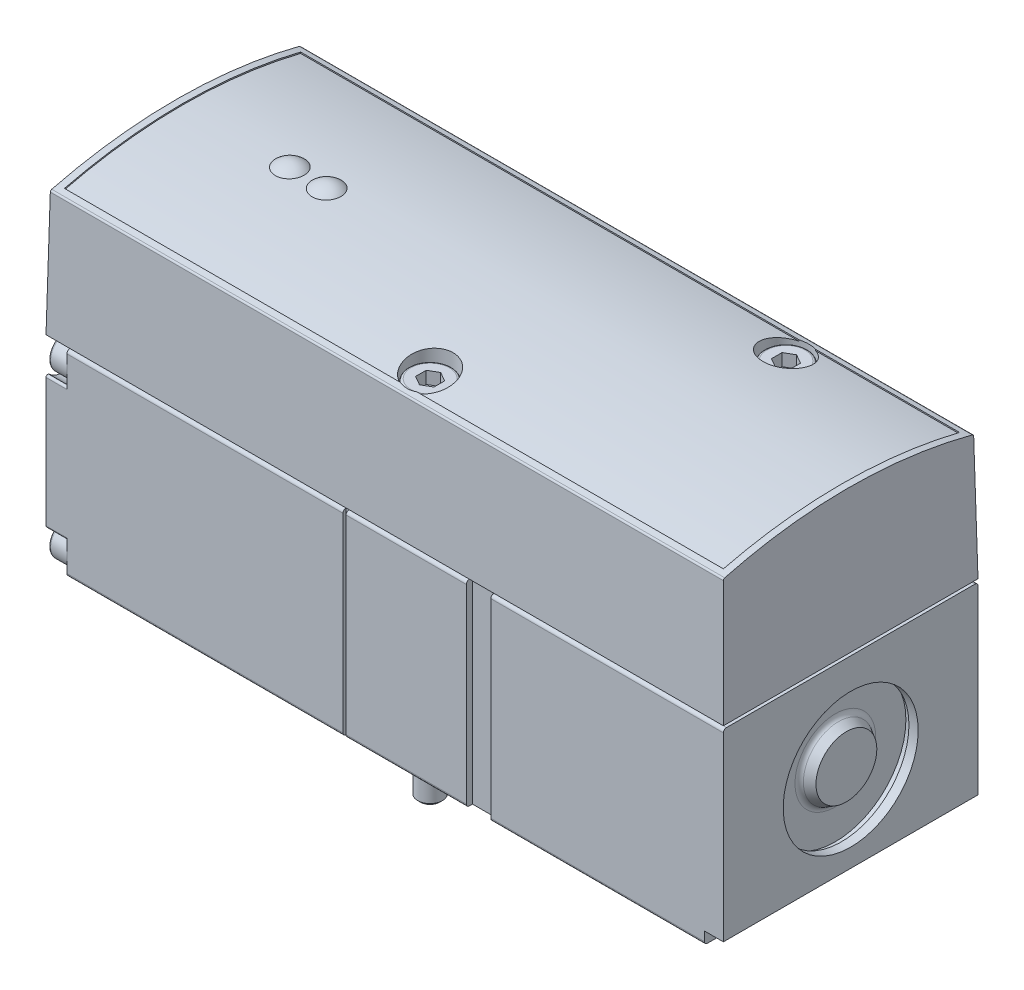
from build123d import *

# Parameters (mm, degrees)
BOSS_EXTRUDE1_DEPTH     = 110.4
SKETCH2_W               = 50
SKETCH2_H               = 40
SKETCH2_W_2             = 40.5
SKETCH2_H_2             = 32
CUT_EXTRUDE1_DEPTH      = 0.5
SKETCH3_W               = 39.7
SKETCH3_H               = 2
BOSS_EXTRUDE2_DEPTH     = 108.6
BOSS_EXTRUDE3_DEPTH     = 110.4
SKETCH5_W               = 107.4
SKETCH5_H               = 38.5
CUT_EXTRUDE2_DEPTH      = 10
BOSS_EXTRUDE4_DEPTH     = 110.4
CUT_EXTRUDE3_DEPTH      = 22
CUT_EXTRUDE3_DEPTH_BACK = 22
CUT_EXTRUDE4_DEPTH      = 3.4
CUT_EXTRUDE5_DEPTH      = 1.3
CUT_EXTRUDE6_DEPTH      = 1.3
CUT_EXTRUDE7_DEPTH      = 1.3
CUT_EXTRUDE8_DEPTH      = 1.3
CUT_EXTRUDE9_DEPTH      = 2
CUT_EXTRUDE10_DEPTH     = 2
SKETCH24_R              = 3
CUT_EXTRUDE11_DEPTH     = 16
CUT_EXTRUDE12_DEPTH     = 5.5
CUT_EXTRUDE13_DEPTH     = 0.4
SKETCH27_R              = 3
CUT_EXTRUDE14_DEPTH     = 16
SKETCH28_R              = 3
CUT_EXTRUDE15_DEPTH     = 16
CUT_EXTRUDE16_DEPTH     = 5.5
SKETCH30_W              = 41.5
SKETCH30_H              = 2
CUT_EXTRUDE17_DEPTH     = 3.1
CUT_EXTRUDE18_DEPTH     = 4
CUT_EXTRUDE19_DEPTH     = 4
CUT_EXTRUDE20_DEPTH     = 6.2
BOSS_EXTRUDE5_DEPTH     = 8.5
CUT_EXTRUDE21_DEPTH     = 3


with BuildPart() as part:
    # Sketch1 → Boss-Extrude1 (new body)
    with BuildSketch(Plane(origin=(0, 0, 0), x_dir=(0, 0, -1), z_dir=(1, 0, 0))):
        with BuildLine():
            Line((-20.75, 31.5), (-20.75, 0.5))
            ThreePointArc((-20.75, 0.5), (-20.603553391, 0.146446609), (-20.25, 0))
            Line((-20.25, 0), (20.25, 0))
            ThreePointArc((20.25, 0), (20.603553391, 0.146446609), (20.75, 0.5))
            Line((20.75, 0.5), (20.75, 31.5))
            ThreePointArc((20.75, 31.5), (20.603553391, 31.853553391), (20.25, 32))
            Line((20.25, 32), (-20.25, 32))
            ThreePointArc((-20.25, 32), (-20.603553391, 31.853553391), (-20.75, 31.5))
        make_face()
    extrude(amount=-BOSS_EXTRUDE1_DEPTH)

    # Sketch2 → Cut-Extrude1 (cut)
    with BuildSketch(Plane(origin=(-61.5, 0, 0), x_dir=(0, 0, -1), z_dir=(1, 0, 0))):
        with Locations((0, 19)):
            Rectangle(SKETCH2_W, SKETCH2_H)
        with Locations((0, 16.5)):
            Rectangle(SKETCH2_W_2, SKETCH2_H_2, mode=Mode.SUBTRACT)
    extrude(amount=-CUT_EXTRUDE1_DEPTH, mode=Mode.SUBTRACT)

    # Sketch3 → Boss-Extrude2 (add)
    with BuildSketch(Plane(origin=(-0.9, 0, 0), x_dir=(0, 0, -1), z_dir=(1, 0, 0))):
        with Locations((0, 32.5)):
            Rectangle(SKETCH3_W, SKETCH3_H)
    extrude(amount=-BOSS_EXTRUDE2_DEPTH)

    # Sketch4 → Boss-Extrude3 (add)
    with BuildSketch(Plane(origin=(0, 0, 0), x_dir=(0, 0, -1), z_dir=(1, 0, 0))):
        with BuildLine():
            Line((-20.75, 32.5), (20.75, 32.5))
            Line((20.75, 32.5), (20.398523638, 52.636067289))
            ThreePointArc((20.398523638, 52.636067289), (20.334276266, 52.816417774), (20.174033257, 52.921185137))
            ThreePointArc((20.174033257, 52.921185137), (-1.9e-08, 55.5), (-20.174033294, 52.921185128))
            ThreePointArc((-20.174033294, 52.921185128), (-20.334276278, 52.816417759), (-20.398523638, 52.636067289))
            Line((-20.398523638, 52.636067289), (-20.75, 32.5))
        make_face()
    extrude(amount=-BOSS_EXTRUDE3_DEPTH)

    # Sketch5 → Cut-Extrude2 (cut)
    with BuildSketch(Plane(origin=(0, 56, 0), x_dir=(1, 0, 0), z_dir=(0, 1, 0))):
        with Locations((-55.2, 0)):
            Rectangle(SKETCH5_W, SKETCH5_H)
    extrude(amount=-CUT_EXTRUDE2_DEPTH, mode=Mode.SUBTRACT)

    # Sketch6 → Boss-Extrude4 (add)
    with BuildSketch(Plane(origin=(0, 0, 0), x_dir=(0, 0, -1), z_dir=(1, 0, 0))):
        with BuildLine():
            Line((-20.75, 32.5), (20.75, 32.5))
            Line((20.75, 32.5), (20.402147424, 52.428460706))
            ThreePointArc((20.402147424, 52.428460706), (20.337964945, 52.608728743), (20.177860123, 52.713525697))
            ThreePointArc((20.177860123, 52.713525697), (1.7e-08, 55.3), (-20.177860091, 52.713525705))
            ThreePointArc((-20.177860091, 52.713525705), (-20.337964935, 52.608728756), (-20.402147424, 52.428460706))
            Line((-20.402147424, 52.428460706), (-20.75, 32.5))
        make_face()
    extrude(amount=-BOSS_EXTRUDE4_DEPTH)

    # Sketch7 → Cut-Extrude3 (cut, two sides)
    with BuildSketch(Plane.XY) as cut_extrude3_sk:
        Polygon((-111.4, 32.5), (-110.4, 32.5), (-109.789072728, 67.5), (-0.610927272, 67.5), (0, 32.5), (1, 32.5), (1, 70), (-111.4, 70), align=None)
    extrude(amount=CUT_EXTRUDE3_DEPTH, mode=Mode.SUBTRACT)
    extrude(cut_extrude3_sk.sketch, amount=-CUT_EXTRUDE3_DEPTH_BACK, mode=Mode.SUBTRACT)

    # Sketch8 → Cut-Extrude4 (cut)
    with BuildSketch(Plane(origin=(-110.4, 0, 0), x_dir=(0, 0, -1), z_dir=(1, 0, 0))):
        with BuildLine():
            Line((-23, 32), (-23, -1))
            Line((-23, -1), (23, -1))
            Line((23, -1), (23, 32))
            Line((23, 32), (15.222363661, 32))
            ThreePointArc((15.222363661, 32), (15.496964107, 31.82080809), (15.443523364, 31.497297297))
            ThreePointArc((15.443523364, 31.497297297), (15.545836944, 26.795836944), (20.247297297, 26.693523364))
            ThreePointArc((20.247297297, 26.693523364), (20.57080809, 26.746964107), (20.75, 26.472363661))
            Line((20.75, 26.472363661), (20.75, 5.527636339))
            ThreePointArc((20.75, 5.527636339), (20.57080809, 5.253035893), (20.247297297, 5.306476636))
            ThreePointArc((20.247297297, 5.306476636), (15.545836944, 5.204163056), (15.443523364, 0.502702703))
            ThreePointArc((15.443523364, 0.502702703), (15.496964107, 0.17919191), (15.222363661, 0))
            Line((15.222363661, 0), (-15.222363661, 0))
            ThreePointArc((-15.222363661, 0), (-15.496964121, 0.179191941), (-15.443523319, 0.502702752))
            ThreePointArc((-15.443523319, 0.502702752), (-15.545836967, 5.20416308), (-20.247297297, 5.306476636))
            ThreePointArc((-20.247297297, 5.306476636), (-20.57080809, 5.253035893), (-20.75, 5.527636339))
            Line((-20.75, 5.527636339), (-20.75, 26.472363661))
            ThreePointArc((-20.75, 26.472363661), (-20.57080809, 26.746964107), (-20.247297297, 26.693523364))
            ThreePointArc((-20.247297297, 26.693523364), (-15.545836944, 26.795836944), (-15.443523364, 31.497297297))
            ThreePointArc((-15.443523364, 31.497297297), (-15.496964107, 31.82080809), (-15.222363661, 32))
            Line((-15.222363661, 32), (-23, 32))
        make_face()
    extrude(amount=CUT_EXTRUDE4_DEPTH, mode=Mode.SUBTRACT)

    # Sketch9 → Revolve1 (revolve)
    with BuildSketch(Plane.XY.offset(-17.95)):
        with BuildLine():
            Line((-110, 2.8), (-110, 5.25))
            ThreePointArc((-110, 5.25), (-109.912132034, 5.462132034), (-109.7, 5.55))
            Line((-109.7, 5.55), (-107, 5.55))
            Line((-107, 5.55), (-107, 2.8))
            Line((-107, 2.8), (-110, 2.8))
        make_face()
    revolve(axis=Axis((-107, 2.8, -17.95), (-1, 0, 0)))

    # Sketch10 → Revolve2 (revolve)
    with BuildSketch(Plane.XY.offset(-17.95)):
        with BuildLine():
            Line((-110, 29.2), (-110, 31.65))
            ThreePointArc((-110, 31.65), (-109.912132034, 31.862132034), (-109.7, 31.95))
            Line((-109.7, 31.95), (-107, 31.95))
            Line((-107, 31.95), (-107, 29.2))
            Line((-107, 29.2), (-110, 29.2))
        make_face()
    revolve(axis=Axis((-107, 29.2, -17.95), (-1, 0, 0)))

    # Sketch11 → Revolve3 (revolve)
    with BuildSketch(Plane.XY.offset(17.95)):
        with BuildLine():
            Line((-110, 2.8), (-110, 5.25))
            ThreePointArc((-110, 5.25), (-109.912132034, 5.462132034), (-109.7, 5.55))
            Line((-109.7, 5.55), (-107, 5.55))
            Line((-107, 5.55), (-107, 2.8))
            Line((-107, 2.8), (-110, 2.8))
        make_face()
    revolve(axis=Axis((-107, 2.8, 17.95), (-1, 0, 0)))

    # Sketch12 → Revolve4 (revolve)
    with BuildSketch(Plane.XY.offset(17.95)):
        with BuildLine():
            Line((-110, 29.2), (-110, 31.65))
            ThreePointArc((-110, 31.65), (-109.912132034, 31.862132034), (-109.7, 31.95))
            Line((-109.7, 31.95), (-107, 31.95))
            Line((-107, 31.95), (-107, 29.2))
            Line((-107, 29.2), (-110, 29.2))
        make_face()
    revolve(axis=Axis((-107, 29.2, 17.95), (-1, 0, 0)))

    # Sketch13 → Cut-Extrude5 (cut)
    with BuildSketch(Plane(origin=(-110, 0, 0), x_dir=(0, 0, -1), z_dir=(1, 0, 0))):
        Polygon((16.7, 3.521687836), (16.7, 2.078312164), (17.95, 1.356624327), (19.2, 2.078312164), (19.2, 3.521687836), (17.95, 4.243375673), align=None)
    extrude(amount=CUT_EXTRUDE5_DEPTH, mode=Mode.SUBTRACT)

    # Sketch14 → Cut-Extrude6 (cut)
    with BuildSketch(Plane(origin=(-110, 0, 0), x_dir=(0, 0, -1), z_dir=(1, 0, 0))):
        Polygon((-19.2, 3.521687836), (-19.2, 2.078312164), (-17.95, 1.356624327), (-16.7, 2.078312164), (-16.7, 3.521687836), (-17.95, 4.243375673), align=None)
    extrude(amount=CUT_EXTRUDE6_DEPTH, mode=Mode.SUBTRACT)

    # Sketch15 → Cut-Extrude7 (cut)
    with BuildSketch(Plane(origin=(-110, 0, 0), x_dir=(0, 0, -1), z_dir=(1, 0, 0))):
        Polygon((16.7, 29.921687836), (16.7, 28.478312164), (17.95, 27.756624327), (19.2, 28.478312164), (19.2, 29.921687836), (17.95, 30.643375673), align=None)
    extrude(amount=CUT_EXTRUDE7_DEPTH, mode=Mode.SUBTRACT)

    # Sketch16 → Cut-Extrude8 (cut)
    with BuildSketch(Plane(origin=(-110, 0, 0), x_dir=(0, 0, -1), z_dir=(1, 0, 0))):
        Polygon((-19.2, 29.921687836), (-19.2, 28.478312164), (-17.95, 27.756624327), (-16.7, 28.478312164), (-16.7, 29.921687836), (-17.95, 30.643375673), align=None)
    extrude(amount=CUT_EXTRUDE8_DEPTH, mode=Mode.SUBTRACT)

    # Sketch17 → Cut-Revolve1 (revolve, cut)
    with BuildSketch(Plane(origin=(-52.8, 0, 0), x_dir=(0, 0, -1), z_dir=(1, 0, 0))):
        Polygon((-15.75, -11.4), (-17.95, -11.4), (-17.95, 48.6), (-19.5, 48.6), (-19.5, 56.6), (-15.75, 56.6), align=None)
    revolve(axis=Axis((-52.8, 56.6, 15.75), (0, -1, 0)), mode=Mode.SUBTRACT)

    # Sketch18 → Cut-Revolve2 (revolve, cut)
    with BuildSketch(Plane(origin=(-26.3, 0, 0), x_dir=(0, 0, -1), z_dir=(1, 0, 0))):
        Polygon((15.75, -11.4), (13.55, -11.4), (13.55, 48.6), (12, 48.6), (12, 56.6), (15.75, 56.6), align=None)
    revolve(axis=Axis((-26.3, 56.6, -15.75), (0, -1, 0)), mode=Mode.SUBTRACT)

    # Sketch19 → Revolve5 (revolve)
    with BuildSketch(Plane(origin=(-52.8, 0, 0), x_dir=(0, 0, -1), z_dir=(1, 0, 0))):
        with BuildLine():
            Line((-15.75, -6.4), (-17.3205, -6.4))
            Line((-17.3205, -6.4), (-17.75, -5.9705))
            Line((-17.75, -5.9705), (-17.75, 48.6))
            Line((-17.75, 48.6), (-19.25, 48.6))
            Line((-19.25, 48.6), (-19.25, 52.2))
            ThreePointArc((-19.25, 52.2), (-19.132842712, 52.482842712), (-18.85, 52.6))
            Line((-18.85, 52.6), (-15.75, 52.6))
            Line((-15.75, 52.6), (-15.75, -6.4))
        make_face()
    revolve(axis=Axis((-52.8, 52.6, 15.75), (0, -1, 0)))

    # Sketch20 → Revolve6 (revolve)
    with BuildSketch(Plane(origin=(-26.3, 0, 0), x_dir=(0, 0, -1), z_dir=(1, 0, 0))):
        with BuildLine():
            Line((15.75, -6.4), (14.1795, -6.4))
            Line((14.1795, -6.4), (13.75, -5.9705))
            Line((13.75, -5.9705), (13.75, 48.6))
            Line((13.75, 48.6), (12.25, 48.6))
            Line((12.25, 48.6), (12.25, 52.2))
            ThreePointArc((12.25, 52.2), (12.367157288, 52.482842712), (12.65, 52.6))
            Line((12.65, 52.6), (15.75, 52.6))
            Line((15.75, 52.6), (15.75, -6.4))
        make_face()
    revolve(axis=Axis((-26.3, 52.6, -15.75), (0, -1, 0)))

    # Sketch21 → Cut-Extrude9 (cut)
    with BuildSketch(Plane(origin=(0, 52.6, 0), x_dir=(1, 0, 0), z_dir=(0, 1, 0))):
        Polygon((-54.3, -16.616025404), (-52.8, -17.482050808), (-51.3, -16.616025404), (-51.3, -14.883974596), (-52.8, -14.017949192), (-54.3, -14.883974596), align=None)
    extrude(amount=-CUT_EXTRUDE9_DEPTH, mode=Mode.SUBTRACT)

    # Sketch22 → Cut-Extrude10 (cut)
    with BuildSketch(Plane(origin=(0, 52.6, 0), x_dir=(1, 0, 0), z_dir=(0, 1, 0))):
        Polygon((-27.8, 14.883974596), (-26.3, 14.017949192), (-24.8, 14.883974596), (-24.8, 16.616025404), (-26.3, 17.482050808), (-27.8, 16.616025404), align=None)
    extrude(amount=-CUT_EXTRUDE10_DEPTH, mode=Mode.SUBTRACT)

    # Sketch23 → Cut-Revolve3 (revolve, cut)
    with BuildSketch(Plane.XY):
        with BuildLine():
            Line((-0.7, 16), (-0.7, 20.960769515))
            Line((-0.7, 20.960769515), (-2, 21.711324865))
            ThreePointArc((-2, 21.711324865), (-2.366025404, 22.077350269), (-2.5, 22.577350269))
            Line((-2.5, 22.577350269), (-2.5, 27.5))
            Line((-2.5, 27.5), (-1.5, 27.5))
            Line((-1.5, 27.5), (-1.5, 27))
            Line((-1.5, 27), (0, 27))
            Line((0, 27), (0, 16))
            Line((0, 16), (-0.7, 16))
        make_face()
    revolve(axis=Axis((0, 16, 0), (-1, 0, 0)), mode=Mode.SUBTRACT)

    # Sketch24 → Cut-Extrude11 (cut)
    with BuildSketch(Plane(origin=(0, 0, 0), x_dir=(1, 0, 0), z_dir=(0, 1, 0))):
        with Locations((-12.2, -7.6)):
            Circle(SKETCH24_R)
    extrude(amount=CUT_EXTRUDE11_DEPTH, mode=Mode.SUBTRACT)

    # Sketch25 → Cut-Extrude12 (cut)
    with BuildSketch(Plane(origin=(0, 0, 0), x_dir=(1, 0, 0), z_dir=(0, 1, 0))):
        with BuildLine():
            Line((-21.921320344, -2.121320344), (-14.321320344, -9.721320344))
            ThreePointArc((-14.321320344, -9.721320344), (-10.078679656, -9.721320344), (-10.078679656, -5.478679656))
            Line((-10.078679656, -5.478679656), (-17.678679656, 2.121320344))
            ThreePointArc((-17.678679656, 2.121320344), (-21.921320292, 2.121320292), (-21.921320344, -2.121320344))
        make_face()
    extrude(amount=CUT_EXTRUDE12_DEPTH, mode=Mode.SUBTRACT)

    # Sketch26 → Cut-Extrude13 (cut)
    with BuildSketch(Plane(origin=(0, 0, 0), x_dir=(1, 0, 0), z_dir=(0, 1, 0))):
        with BuildLine():
            Line((-41.3, 1.25), (-39.3, 1.25))
            Line((-39.3, 1.25), (-39.3, -1.694671206))
            ThreePointArc((-39.3, -1.694671206), (-43.937966579, -9.769619282), (-36.8, -15.75))
            Line((-36.8, -15.75), (-28.3, -15.75))
            ThreePointArc((-28.3, -15.75), (-25.525545115, -15.198126611), (-23.173475836, -13.626524164))
            Line((-23.173475836, -13.626524164), (-19.8, -10.253048327))
            Line((-19.8, -10.253048327), (-17.326524164, -12.726524164))
            ThreePointArc((-17.326524164, -12.726524164), (-7.073475836, -12.726524164), (-7.073475836, -2.473475836))
            Line((-7.073475836, -2.473475836), (-14.674873734, 5.127922061))
            ThreePointArc((-14.674873734, 5.127922061), (-22.509952189, 6.72644315), (-27.05, 0.14376209))
            Line((-27.05, 0.14376209), (-27.05, -1.25))
            Line((-27.05, -1.25), (-36.8, -1.25))
            Line((-36.8, -1.25), (-36.8, 1.694671206))
            ThreePointArc((-36.8, 1.694671206), (-32.162033421, 9.769619282), (-39.3, 15.75))
            Line((-39.3, 15.75), (-41.3, 15.75))
            ThreePointArc((-41.3, 15.75), (-48.55, 8.5), (-41.3, 1.25))
        make_face()
        with BuildLine():
            Line((-24.55, -0.11383263), (-24.55, -1.967514421))
            Line((-24.55, -1.967514421), (-15.558757211, -10.958757211))
            ThreePointArc((-15.558757211, -10.958757211), (-8.841242789, -10.958757211), (-8.841242789, -4.241242789))
            Line((-8.841242789, -4.241242789), (-16.442640687, 3.360155108))
            ThreePointArc((-16.442640687, 3.360155108), (-21.672243938, 4.367452764), (-24.55, -0.11383263))
        make_face(mode=Mode.SUBTRACT)
        with BuildLine():
            Line((-36.8, -13.25), (-28.3, -13.25))
            ThreePointArc((-28.3, -13.25), (-26.482253696, -12.888427779), (-24.941242789, -11.858757211))
            Line((-24.941242789, -11.858757211), (-21.566242789, -8.483757211))
            Line((-21.566242789, -8.483757211), (-26.3, -3.75))
            Line((-26.3, -3.75), (-36.8, -3.75))
            ThreePointArc((-36.8, -3.75), (-41.55, -8.5), (-36.8, -13.25))
        make_face(mode=Mode.SUBTRACT)
        with BuildLine():
            Line((-41.3, 3.75), (-39.3, 3.75))
            ThreePointArc((-39.3, 3.75), (-34.55, 8.5), (-39.3, 13.25))
            Line((-39.3, 13.25), (-41.3, 13.25))
            ThreePointArc((-41.3, 13.25), (-46.05, 8.5), (-41.3, 3.75))
        make_face(mode=Mode.SUBTRACT)
    extrude(amount=CUT_EXTRUDE13_DEPTH, mode=Mode.SUBTRACT)

    # Sketch27 → Cut-Extrude14 (cut)
    with BuildSketch(Plane(origin=(0, 0, 0), x_dir=(1, 0, 0), z_dir=(0, 1, 0))):
        with Locations((-41.3, 8.5)):
            Circle(SKETCH27_R)
    extrude(amount=CUT_EXTRUDE14_DEPTH, mode=Mode.SUBTRACT)

    # Sketch28 → Cut-Extrude15 (cut)
    with BuildSketch(Plane(origin=(0, 0, 0), x_dir=(1, 0, 0), z_dir=(0, 1, 0))):
        with Locations((-28.3, -8.5)):
            Circle(SKETCH28_R)
    extrude(amount=CUT_EXTRUDE15_DEPTH, mode=Mode.SUBTRACT)

    # Sketch29 → Cut-Extrude16 (cut)
    with BuildSketch(Plane(origin=(0, 0, 0), x_dir=(1, 0, 0), z_dir=(0, 1, 0))):
        with BuildLine():
            Line((-36.8, -11.5), (-28.3, -11.5))
            ThreePointArc((-28.3, -11.5), (-25.3, -8.5), (-28.3, -5.5))
            Line((-28.3, -5.5), (-36.8, -5.5))
            ThreePointArc((-36.8, -5.5), (-39.8, -8.5), (-36.8, -11.5))
        make_face()
    extrude(amount=CUT_EXTRUDE16_DEPTH, mode=Mode.SUBTRACT)

    # Sketch30 → Cut-Extrude17 (cut)
    with BuildSketch(Plane(origin=(0, 0, 0), x_dir=(0, 0, -1), z_dir=(1, 0, 0))):
        with Locations((0, 1)):
            Rectangle(SKETCH30_W, SKETCH30_H)
    extrude(amount=-CUT_EXTRUDE17_DEPTH, mode=Mode.SUBTRACT)

    # Sketch31 → Cut-Extrude18 (cut)
    with BuildSketch(Plane(origin=(-37.9, 0, 0), x_dir=(0, 0, -1), z_dir=(1, 0, 0))):
        Polygon((-22, 32), (-22, -1), (0, -1), (0, 0), (-19.75, 0), (-19.75, 32), align=None)
    extrude(amount=-CUT_EXTRUDE18_DEPTH, mode=Mode.SUBTRACT)

    # Sketch32 → Cut-Extrude19 (cut)
    with BuildSketch(Plane(origin=(-34.1, 0, 0), x_dir=(0, 0, -1), z_dir=(1, 0, 0))):
        Polygon((0, -1), (22, -1), (22, 32), (19.75, 32), (19.75, 0), (0, 0), align=None)
    extrude(amount=-CUT_EXTRUDE19_DEPTH, mode=Mode.SUBTRACT)

    # Sketch33 → Revolve7 (revolve)
    with BuildSketch(Plane.XY):
        with BuildLine():
            Line((-81.94, 52.74), (-94.86, 52.74))
            ThreePointArc((-94.86, 52.74), (-92.29207623, 56.083022584), (-88.4, 54.463832939))
            ThreePointArc((-88.4, 54.463832939), (-84.50792377, 56.083022584), (-81.94, 52.74))
        make_face()
    revolve(axis=Axis((-81.94, 52.74, 0), (-1, 0, 0)))

    # Sketch34 → Cut-Extrude20 (cut)
    with BuildSketch(Plane(origin=(0, 0, 0), x_dir=(1, 0, 0), z_dir=(0, 1, 0))):
        with BuildLine():
            Line((-98.32, 7), (-92.58, 7))
            ThreePointArc((-92.58, 7), (-88.68, 10.9), (-92.58, 14.8))
            Line((-92.58, 14.8), (-98.32, 14.8))
            ThreePointArc((-98.32, 14.8), (-102.22, 10.9), (-98.32, 7))
        make_face()
    extrude(amount=CUT_EXTRUDE20_DEPTH, mode=Mode.SUBTRACT)

    # Sketch35 → Boss-Extrude5 (add)
    with BuildSketch(Plane(origin=(-91.2, 0, 0), x_dir=(0, 0, -1), z_dir=(1, 0, 0))):
        Polygon((9.625, 2.4192), (9.777356124, 1.962), (9.972643876, 1.962), (10.125, 2.4192), (10.125, 6.762), (11.625, 6.762), (11.625, 2.4192), (11.777356124, 1.962), (11.972643876, 1.962), (12.125, 2.4192), (12.125, 6.962), (9.625, 6.962), align=None)
    extrude(amount=-BOSS_EXTRUDE5_DEPTH)

    # Sketch36 → Cut-Extrude21 (cut)
    with BuildSketch(Plane.XY.offset(-9.625)):
        Polygon((-100, 1.2), (-91, 1.2), (-91, 6.2), (-91.2, 6.2), (-91.2, 2.4192), (-91.352356124, 1.962), (-91.547643876, 1.962), (-91.7, 2.4192), (-91.7, 6.2), (-93.2, 6.2), (-93.2, 2.4192), (-93.352356124, 1.962), (-93.547643876, 1.962), (-93.7, 2.4192), (-93.7, 6.2), (-95.2, 6.2), (-95.2, 2.4192), (-95.352356124, 1.962), (-95.547643876, 1.962), (-95.7, 2.4192), (-95.7, 6.2), (-97.2, 6.2), (-97.2, 2.4192), (-97.352356124, 1.962), (-97.547643876, 1.962), (-97.7, 2.4192), (-97.7, 6.2), (-99.2, 6.2), (-99.2, 2.4192), (-99.352356124, 1.962), (-99.547643876, 1.962), (-99.7, 2.4192), (-99.7, 6.2), (-100, 6.2), align=None)
    extrude(amount=-CUT_EXTRUDE21_DEPTH, mode=Mode.SUBTRACT)


solid = part.part
